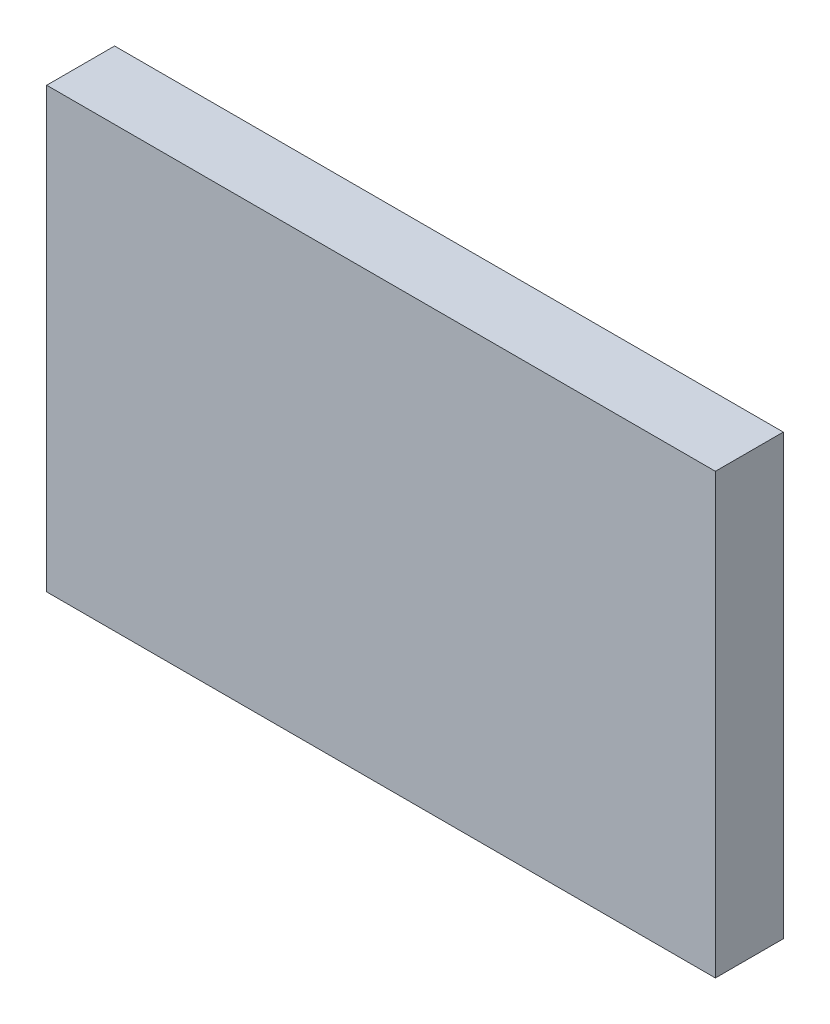
from build123d import *

# Parameters (mm, degrees)
ESQUISSE1_W        = 64
ESQUISSE1_H        = 42
BOSS_EXTRU_1_DEPTH = 6.5


with BuildPart() as part:
    # Esquisse1 → Boss.-Extru.1 (new body)
    with BuildSketch(Plane.XY):
        with Locations((32, 21)):
            Rectangle(ESQUISSE1_W, ESQUISSE1_H)
    extrude(amount=BOSS_EXTRU_1_DEPTH)


solid = part.part
